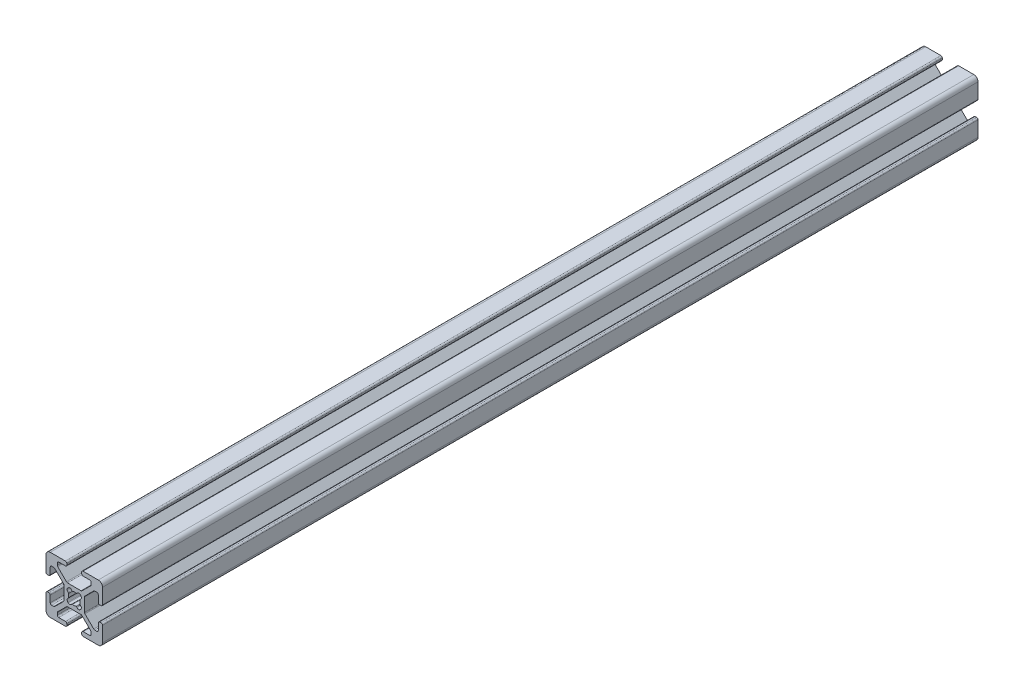
from build123d import *

# Parameters (mm, degrees)
F_20_SERIES_20_2020_1_DEPTH = 310


with BuildPart() as part:
    # Sketch11 → 20_series 20-2020(1) (new body)
    with BuildSketch(Plane.YX):
        with BuildLine():
            Line((9.0094, 2.6289), (9.492, 2.6289))
            ThreePointArc((9.492, 2.6289), (9.851210245, 2.777689755), (10, 3.1369))
            Line((10, 3.1369), (10, 8.5014))
            ThreePointArc((10, 8.5014), (9.561070222, 9.561070222), (8.5014, 10))
            Line((8.5014, 10), (3.1369, 10))
            ThreePointArc((3.1369, 10), (2.777689755, 9.851210245), (2.6289, 9.492))
            Line((2.6289, 9.492), (2.6289, 9.0094))
            ThreePointArc((2.6289, 9.0094), (2.777689755, 8.650189755), (3.1369, 8.5014))
            Line((3.1369, 8.5014), (5.4864, 8.5014))
            ThreePointArc((5.4864, 8.5014), (5.845610245, 8.352610245), (5.9944, 7.9934))
            Line((5.9944, 7.9934), (5.9944, 7.264490712))
            ThreePointArc((5.9944, 7.264490712), (5.955730803, 7.070087528), (5.845610245, 6.905280467))
            Line((5.845610245, 6.905280467), (2.747686782, 3.807357004))
            ThreePointArc((2.747686782, 3.807357004), (2.582879721, 3.697236446), (2.388476537, 3.658567249))
            Line((2.388476537, 3.658567249), (-2.388476537, 3.658567249))
            ThreePointArc((-2.388476537, 3.658567249), (-2.582879721, 3.697236446), (-2.747686782, 3.807357004))
            Line((-2.747686782, 3.807357004), (-5.845610245, 6.905280467))
            ThreePointArc((-5.845610245, 6.905280467), (-5.955730803, 7.070087528), (-5.9944, 7.264490712))
            Line((-5.9944, 7.264490712), (-5.9944, 7.9934))
            ThreePointArc((-5.9944, 7.9934), (-5.845610245, 8.352610245), (-5.4864, 8.5014))
            Line((-5.4864, 8.5014), (-3.1369, 8.5014))
            ThreePointArc((-3.1369, 8.5014), (-2.777689755, 8.650189755), (-2.6289, 9.0094))
            Line((-2.6289, 9.0094), (-2.6289, 9.492))
            ThreePointArc((-2.6289, 9.492), (-2.777689755, 9.851210245), (-3.1369, 10))
            Line((-3.1369, 10), (-8.5014, 10))
            ThreePointArc((-8.5014, 10), (-9.561070222, 9.561070222), (-10, 8.5014))
            Line((-10, 8.5014), (-10, 3.1369))
            ThreePointArc((-10, 3.1369), (-9.851210245, 2.777689755), (-9.492, 2.6289))
            Line((-9.492, 2.6289), (-9.0094, 2.6289))
            ThreePointArc((-9.0094, 2.6289), (-8.650189755, 2.777689755), (-8.5014, 3.1369))
            Line((-8.5014, 3.1369), (-8.5014, 5.4864))
            ThreePointArc((-8.5014, 5.4864), (-8.352610245, 5.845610245), (-7.9934, 5.9944))
            Line((-7.9934, 5.9944), (-7.264490712, 5.9944))
            ThreePointArc((-7.264490712, 5.9944), (-7.070087528, 5.955730803), (-6.905280467, 5.845610245))
            Line((-6.905280467, 5.845610245), (-3.807357004, 2.747686782))
            ThreePointArc((-3.807357004, 2.747686782), (-3.697236446, 2.582879721), (-3.658567249, 2.388476537))
            Line((-3.658567249, 2.388476537), (-3.658567249, -2.388476537))
            ThreePointArc((-3.658567249, -2.388476537), (-3.697236446, -2.582879721), (-3.807357004, -2.747686782))
            Line((-3.807357004, -2.747686782), (-6.905280467, -5.845610245))
            ThreePointArc((-6.905280467, -5.845610245), (-7.070087528, -5.955730803), (-7.264490712, -5.9944))
            Line((-7.264490712, -5.9944), (-7.9934, -5.9944))
            ThreePointArc((-7.9934, -5.9944), (-8.352610245, -5.845610245), (-8.5014, -5.4864))
            Line((-8.5014, -5.4864), (-8.5014, -3.1369))
            ThreePointArc((-8.5014, -3.1369), (-8.650189755, -2.777689755), (-9.0094, -2.6289))
            Line((-9.0094, -2.6289), (-9.492, -2.6289))
            ThreePointArc((-9.492, -2.6289), (-9.851210245, -2.777689755), (-10, -3.1369))
            Line((-10, -3.1369), (-10, -8.5014))
            ThreePointArc((-10, -8.5014), (-9.561070222, -9.561070222), (-8.5014, -10))
            Line((-8.5014, -10), (-3.1369, -10))
            ThreePointArc((-3.1369, -10), (-2.777689755, -9.851210245), (-2.6289, -9.492))
            Line((-2.6289, -9.492), (-2.6289, -9.0094))
            ThreePointArc((-2.6289, -9.0094), (-2.777689755, -8.650189755), (-3.1369, -8.5014))
            Line((-3.1369, -8.5014), (-5.4864, -8.5014))
            ThreePointArc((-5.4864, -8.5014), (-5.845610245, -8.352610245), (-5.9944, -7.9934))
            Line((-5.9944, -7.9934), (-5.9944, -7.264490712))
            ThreePointArc((-5.9944, -7.264490712), (-5.955730803, -7.070087528), (-5.845610245, -6.905280467))
            Line((-5.845610245, -6.905280467), (-2.747686782, -3.807357004))
            ThreePointArc((-2.747686782, -3.807357004), (-2.582879721, -3.697236446), (-2.388476537, -3.658567249))
            Line((-2.388476537, -3.658567249), (2.388476537, -3.658567249))
            ThreePointArc((2.388476537, -3.658567249), (2.582879721, -3.697236446), (2.747686782, -3.807357004))
            Line((2.747686782, -3.807357004), (5.845610245, -6.905280467))
            ThreePointArc((5.845610245, -6.905280467), (5.955730803, -7.070087528), (5.9944, -7.264490712))
            Line((5.9944, -7.264490712), (5.9944, -7.9934))
            ThreePointArc((5.9944, -7.9934), (5.845610245, -8.352610245), (5.4864, -8.5014))
            Line((5.4864, -8.5014), (3.1369, -8.5014))
            ThreePointArc((3.1369, -8.5014), (2.777689755, -8.650189755), (2.6289, -9.0094))
            Line((2.6289, -9.0094), (2.6289, -9.492))
            ThreePointArc((2.6289, -9.492), (2.777689755, -9.851210245), (3.1369, -10))
            Line((3.1369, -10), (8.5014, -10))
            ThreePointArc((8.5014, -10), (9.561070222, -9.561070222), (10, -8.5014))
            Line((10, -8.5014), (10, -3.1369))
            ThreePointArc((10, -3.1369), (9.851210245, -2.777689755), (9.492, -2.6289))
            Line((9.492, -2.6289), (9.0094, -2.6289))
            ThreePointArc((9.0094, -2.6289), (8.650189755, -2.777689755), (8.5014, -3.1369))
            Line((8.5014, -3.1369), (8.5014, -5.4864))
            ThreePointArc((8.5014, -5.4864), (8.352610245, -5.845610245), (7.9934, -5.9944))
            Line((7.9934, -5.9944), (7.264490712, -5.9944))
            ThreePointArc((7.264490712, -5.9944), (7.070087528, -5.955730803), (6.905280467, -5.845610245))
            Line((6.905280467, -5.845610245), (3.807357004, -2.747686782))
            ThreePointArc((3.807357004, -2.747686782), (3.697236446, -2.582879721), (3.658567249, -2.388476537))
            Line((3.658567249, -2.388476537), (3.658567249, 2.388476537))
            ThreePointArc((3.658567249, 2.388476537), (3.697236446, 2.582879721), (3.807357004, 2.747686782))
            Line((3.807357004, 2.747686782), (6.905280467, 5.845610245))
            ThreePointArc((6.905280467, 5.845610245), (7.070087528, 5.955730803), (7.264490712, 5.9944))
            Line((7.264490712, 5.9944), (7.9934, 5.9944))
            ThreePointArc((7.9934, 5.9944), (8.352610245, 5.845610245), (8.5014, 5.4864))
            Line((8.5014, 5.4864), (8.5014, 3.1369))
            ThreePointArc((8.5014, 3.1369), (8.650189755, 2.777689755), (9.0094, 2.6289))
        make_face()
        with BuildLine():
            Line((-2.296558466, 2.121727546), (-2.121727546, 2.296558466))
            ThreePointArc((-2.121727546, 2.296558466), (-1.459775814, 2.520126613), (-0.880635441, 2.129282347))
            ThreePointArc((-0.880635441, 2.129282347), (-0.755121693, 2.019456424), (-0.588548999, 2.011151493))
            ThreePointArc((-0.588548999, 2.011151493), (0, 2.0955), (0.588548999, 2.011151493))
            ThreePointArc((0.588548999, 2.011151493), (0.755121693, 2.019456424), (0.880635441, 2.129282347))
            ThreePointArc((0.880635441, 2.129282347), (1.459775814, 2.520126613), (2.121727546, 2.296558466))
            Line((2.121727546, 2.296558466), (2.296558466, 2.121727546))
            ThreePointArc((2.296558466, 2.121727546), (2.520126613, 1.459775814), (2.129282347, 0.880635441))
            ThreePointArc((2.129282347, 0.880635441), (2.019456424, 0.755121693), (2.011151493, 0.588548999))
            ThreePointArc((2.011151493, 0.588548999), (2.0955, 0), (2.011151493, -0.588548999))
            ThreePointArc((2.011151493, -0.588548999), (2.019456424, -0.755121693), (2.129282347, -0.880635441))
            ThreePointArc((2.129282347, -0.880635441), (2.520126613, -1.459775814), (2.296558466, -2.121727546))
            Line((2.296558466, -2.121727546), (2.121727546, -2.296558466))
            ThreePointArc((2.121727546, -2.296558466), (1.459775814, -2.520126613), (0.880635441, -2.129282347))
            ThreePointArc((0.880635441, -2.129282347), (0.755121693, -2.019456424), (0.588548999, -2.011151493))
            ThreePointArc((0.588548999, -2.011151493), (0, -2.0955), (-0.588548999, -2.011151493))
            ThreePointArc((-0.588548999, -2.011151493), (-0.755121693, -2.019456424), (-0.880635441, -2.129282347))
            ThreePointArc((-0.880635441, -2.129282347), (-1.459775814, -2.520126613), (-2.121727546, -2.296558466))
            Line((-2.121727546, -2.296558466), (-2.296558466, -2.121727546))
            ThreePointArc((-2.296558466, -2.121727546), (-2.520126613, -1.459775814), (-2.129282347, -0.880635441))
            ThreePointArc((-2.129282347, -0.880635441), (-2.019456424, -0.755121693), (-2.011151493, -0.588548999))
            ThreePointArc((-2.011151493, -0.588548999), (-2.0955, 0), (-2.011151493, 0.588548999))
            ThreePointArc((-2.011151493, 0.588548999), (-2.019456424, 0.755121693), (-2.129282347, 0.880635441))
            ThreePointArc((-2.129282347, 0.880635441), (-2.520126613, 1.459775814), (-2.296558466, 2.121727546))
        make_face(mode=Mode.SUBTRACT)
    extrude(amount=F_20_SERIES_20_2020_1_DEPTH)


solid = part.part
